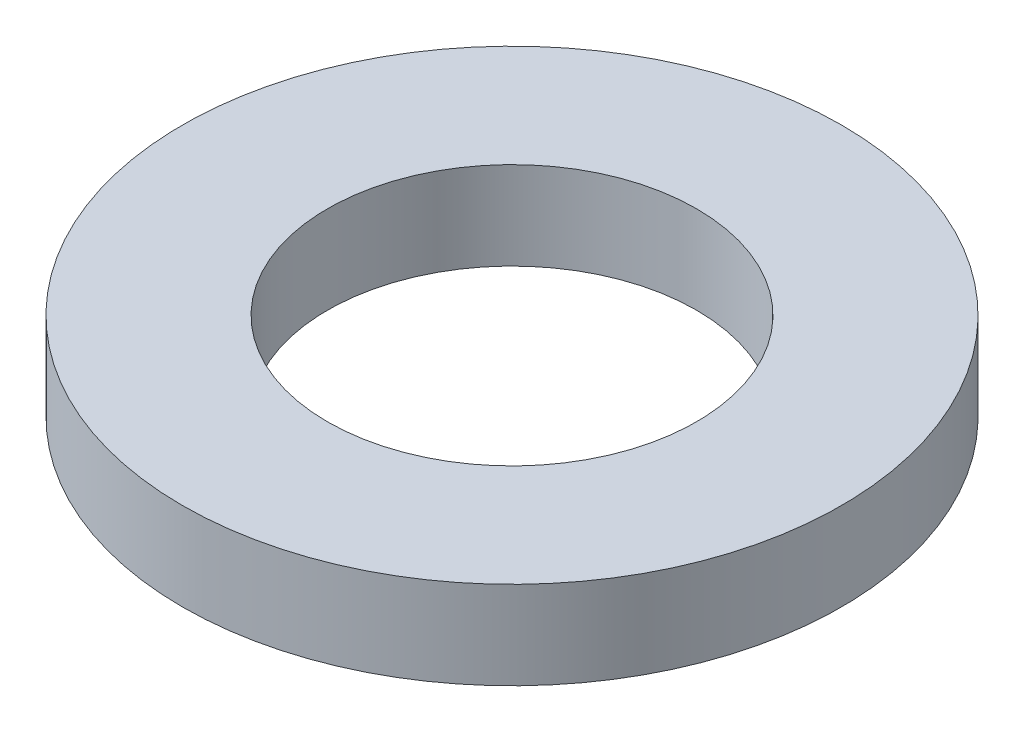
from build123d import *

# Parameters (mm, degrees)
SKETCH_1_R      = 7.5
SKETCH_1_R_2    = 4.2
EXTRUDE_1_DEPTH = 2


with BuildPart() as part:
    # Эскиз1 → Вытянуть1 (new body)
    with BuildSketch(Plane(origin=(0, 0, 0), x_dir=(1, 0, 0), z_dir=(0, 1, 0))):
        Circle(SKETCH_1_R)
        Circle(SKETCH_1_R_2, mode=Mode.SUBTRACT)
    extrude(amount=EXTRUDE_1_DEPTH)


solid = part.part
